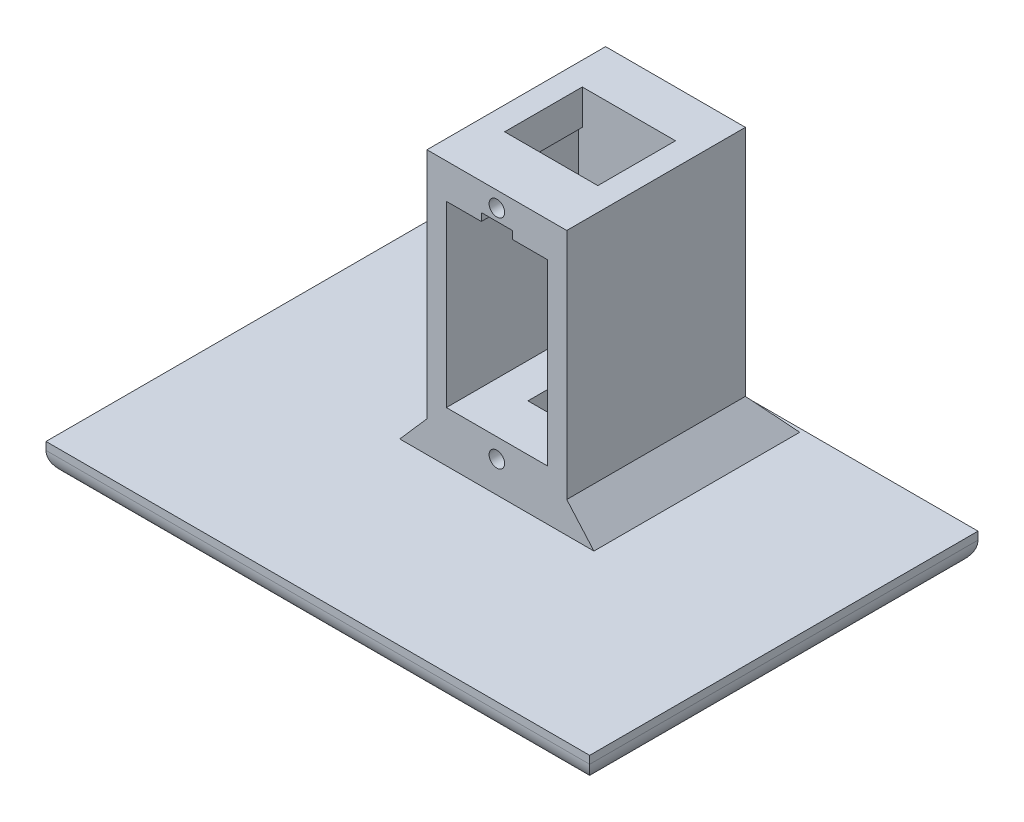
from build123d import *

# Parameters (mm, degrees)
BOSS_EXTRUDE1_DEPTH     = 22
SKETCH2_W               = 18.000000089
SKETCH2_H               = 20
BOSS_EXTRUDE2_DEPTH     = 7
SKETCH3_W               = 70
SKETCH3_H               = 50
BOSS_EXTRUDE3_DEPTH     = 4
SKETCH31_W              = 18.000000089
SKETCH31_H              = 3
BOSS_EXTRUDE7_DEPTH     = 34
CUT_EXTRUDE1_REACH      = 52
CUT_EXTRUDE_THIN1_REACH = 72
SKETCH7_W               = 25.000000089
SKETCH7_H               = 30
SKETCH8_W               = 18.000000089
SKETCH8_H               = 23
CUT_EXTRUDE2_DEPTH      = 27.000000055
CUT_EXTRUDE2_DEPTH_BACK = 45.000000145
SKETCH10_R              = 1
CUT_EXTRUDE3_DEPTH      = 10
SKETCH12_W              = 4
SKETCH12_H              = 5
CUT_EXTRUDE4_DEPTH      = 4
SKETCH13_W              = 18.000000089
SKETCH13_H              = 23
BOSS_EXTRUDE4_DEPTH     = 5
SKETCH14_R              = 1
CUT_EXTRUDE5_DEPTH      = 10
CUT_EXTRUDE6_REACH      = 40
CUT_EXTRUDE10_START     = -17
SKETCH29_W              = 13
SKETCH29_H              = 23
CUT_EXTRUDE10_DEPTH     = 17
SKETCH30_W              = 4
SKETCH30_H              = 1
CUT_EXTRUDE11_DEPTH     = 7
SKETCH21_R              = 5
CUT_EXTRUDE12_DEPTH     = 6
SKETCH32_R              = 4.999999958
BOSS_EXTRUDE8_DEPTH     = 2
CUT_EXTRUDE13_REACH     = 44.05
SKETCH33_R              = 1.5
SKETCH34_R              = 2.5
CUT_EXTRUDE14_DEPTH     = 1


with BuildPart() as part:
    # Sketch1 → Boss-Extrude1 (new body)
    with BuildSketch(Plane.XZ.offset(109.542579658)):
        Polygon((23.483775445, -24.37606884), (23.483775445, -44.37606884), (5.483775356, -44.37606884), (5.483775356, -24.37606884), (8.483775356, -24.37606884), (8.483775445, -41.37606884), (20.483775445, -41.37606884), (20.483775445, -24.37606884), align=None)
    extrude(amount=-BOSS_EXTRUDE1_DEPTH)

    # Sketch2 → Boss-Extrude2 (add)
    with BuildSketch(Plane.XZ.offset(109.542579658)):
        with Locations((14.483775401, -34.37606884)):
            Rectangle(SKETCH2_W, SKETCH2_H)
    extrude(amount=BOSS_EXTRUDE2_DEPTH)

    # Sketch3 → Boss-Extrude3 (add)
    with BuildSketch(Plane.XZ.offset(116.542579658)):
        with Locations((14.4837754, -26.325627156)):
            Rectangle(SKETCH3_W, SKETCH3_H)
    extrude(amount=BOSS_EXTRUDE3_DEPTH)

    # Sketch31 → Boss-Extrude7 (add)
    with BuildSketch(Plane(origin=(0, -116.542579658, 0), x_dir=(1, 0, 0), z_dir=(0, 1, 0))):
        with Locations((14.483775401, 45.87606884)):
            Rectangle(SKETCH31_W, SKETCH31_H)
    extrude(amount=BOSS_EXTRUDE7_DEPTH)

    # Sketch4 → Cut-Extrude1 (cut, up to next)
    with BuildSketch(Plane(origin=(0, 0, -51.325627156), x_dir=(-1, 0, 0), z_dir=(0, 0, -1)), mode=Mode.PRIVATE) as cut_extrude1_sk1:
        with BuildLine():
            Line((-49.4837754, -117.542579658), (-49.4837754, -120.542579658))
            Line((-49.4837754, -120.542579658), (-46.4837754, -120.542579658))
            ThreePointArc((-46.4837754, -120.542579658), (-48.605095744, -119.663900001), (-49.4837754, -117.542579658))
        make_face()
    cut_extrude1_tool1 = extrude(cut_extrude1_sk1.sketch, amount=-CUT_EXTRUDE1_REACH, mode=Mode.PRIVATE) & part.part
    add(cut_extrude1_tool1.solids().sort_by_distance((48.813672, -119.872476, -51.325627))[0], mode=Mode.SUBTRACT)
    # Sketch4 → Cut-Extrude1 (cut, up to next)
    with BuildSketch(Plane(origin=(0, 0, -51.325627156), x_dir=(-1, 0, 0), z_dir=(0, 0, -1)), mode=Mode.PRIVATE) as cut_extrude1_sk2:
        with BuildLine():
            Line((17.5162246, -120.542579658), (20.5162246, -120.542579658))
            Line((20.5162246, -120.542579658), (20.5162246, -117.542579658))
            ThreePointArc((20.5162246, -117.542579658), (19.637544943, -119.663900001), (17.5162246, -120.542579658))
        make_face()
    cut_extrude1_tool2 = extrude(cut_extrude1_sk2.sketch, amount=-CUT_EXTRUDE1_REACH, mode=Mode.PRIVATE) & part.part
    add(cut_extrude1_tool2.solids().sort_by_distance((-19.846121, -119.872476, -51.325627))[0], mode=Mode.SUBTRACT)

    # Sketch6 → Cut-Extrude-Thin1 (cut, up to next)
    with BuildSketch(Plane.ZY.offset(20.5162246), mode=Mode.PRIVATE) as cut_extrude_thin1_sk1:
        with BuildLine():
            ThreePointArc((-4.325627156, -120.542579658), (-2.204306812, -119.663900001), (-1.325627156, -117.542579658))
            Line((-1.325627156, -117.542579658), (8.674372844, -117.542579658))
            ThreePointArc((8.674372844, -117.542579658), (4.866761, -126.734967813), (-4.325627156, -130.542579658))
            Line((-4.325627156, -130.542579658), (-4.325627156, -120.542579658))
        make_face()
    cut_extrude_thin1_tool1 = extrude(cut_extrude_thin1_sk1.sketch, amount=-CUT_EXTRUDE_THIN1_REACH, mode=Mode.PRIVATE) & part.part
    add(cut_extrude_thin1_tool1.solids().sort_by_distance((-20.516225, -123.298683, 1.430477))[0], mode=Mode.SUBTRACT)
    # Sketch6 → Cut-Extrude-Thin1 (cut, up to next)
    with BuildSketch(Plane.ZY.offset(20.5162246), mode=Mode.PRIVATE) as cut_extrude_thin1_sk2:
        with BuildLine():
            ThreePointArc((-51.325627156, -117.542579658), (-50.446947499, -119.663900001), (-48.325627156, -120.542579658))
            Line((-48.325627156, -120.542579658), (-48.325627156, -130.542579658))
            ThreePointArc((-48.325627156, -130.542579658), (-57.518015311, -126.734967813), (-61.325627156, -117.542579658))
            Line((-61.325627156, -117.542579658), (-51.325627156, -117.542579658))
        make_face()
    cut_extrude_thin1_tool2 = extrude(cut_extrude_thin1_sk2.sketch, amount=-CUT_EXTRUDE_THIN1_REACH, mode=Mode.PRIVATE) & part.part
    add(cut_extrude_thin1_tool2.solids().sort_by_distance((-20.516225, -123.298683, -54.081731))[0], mode=Mode.SUBTRACT)

    # Sketch7 → Loft2 section 0
    with BuildSketch(Plane(origin=(0, -116.542579658, 0), x_dir=(1, 0, 0), z_dir=(0, 1, 0))):
        with Locations((14.483775401, 35.87606884)):
            Rectangle(SKETCH7_W, SKETCH7_H)
    # Sketch8 → Loft2 section 1
    with BuildSketch(Plane(origin=(0, -112.542579658, 0), x_dir=(1, 0, 0), z_dir=(0, 1, 0))):
        with Locations((14.483775401, 35.87606884)):
            Rectangle(SKETCH8_W, SKETCH8_H)
    loft()

    # Sketch9 → Cut-Extrude2 (cut, two sides)
    with BuildSketch(Plane.ZY.offset(-5.483775356)) as cut_extrude2_sk:
        Polygon((-24.37606884, -112.542579658), (-24.37606884, -116.542579658), (-20.87606884, -116.542579658), align=None)
    extrude(amount=CUT_EXTRUDE2_DEPTH, mode=Mode.SUBTRACT)
    extrude(cut_extrude2_sk.sketch, amount=-CUT_EXTRUDE2_DEPTH_BACK, mode=Mode.SUBTRACT)

    # Sketch10 → Cut-Extrude3 (cut)
    with BuildSketch(Plane.XY.offset(-24.37606884)):
        with Locations((14.483775445, -112.542579896)):
            Circle(SKETCH10_R)
    extrude(amount=-CUT_EXTRUDE3_DEPTH, mode=Mode.SUBTRACT)

    # Sketch12 → Cut-Extrude4 (cut)
    with BuildSketch(Plane.XY.offset(-34.37606884)):
        with Locations((14.483775445, -112.042579658)):
            Rectangle(SKETCH12_W, SKETCH12_H)
    extrude(amount=CUT_EXTRUDE4_DEPTH, mode=Mode.SUBTRACT)

    # Sketch13 → Boss-Extrude4 (add)
    with BuildSketch(Plane(origin=(0, -87.542579658, 0), x_dir=(1, 0, 0), z_dir=(0, 1, 0))):
        with Locations((14.483775401, 35.87606884)):
            Rectangle(SKETCH13_W, SKETCH13_H)
    extrude(amount=BOSS_EXTRUDE4_DEPTH)

    # Sketch14 → Cut-Extrude5 (cut)
    with BuildSketch(Plane.XY.offset(-24.37606884)):
        with Locations((14.483775445, -84.542579419)):
            Circle(SKETCH14_R)
    extrude(amount=-CUT_EXTRUDE5_DEPTH, mode=Mode.SUBTRACT)

    # Sketch16 → Cut-Extrude6 (cut, up to next)
    with BuildSketch(Plane(origin=(0, -82.542579658, 0), x_dir=(1, 0, 0), z_dir=(0, 1, 0)), mode=Mode.PRIVATE) as cut_extrude6_sk1:
        Polygon((14.4837754, 41.37606884), (8.4837754, 41.37606884), (8.4837754, 31.37606884), (20.4837754, 31.37606884), (20.4837754, 41.37606884), align=None)
    cut_extrude6_tool1 = extrude(cut_extrude6_sk1.sketch, amount=-CUT_EXTRUDE6_REACH, mode=Mode.PRIVATE) & part.part
    add(cut_extrude6_tool1.solids().sort_by_distance((14.483775, -82.54258, -36.376069))[0], mode=Mode.SUBTRACT)

    # Sketch29 → Cut-Extrude10 (cut)
    with BuildSketch(Plane.XY.offset(-24.37606884).offset(CUT_EXTRUDE10_START)):
        with Locations((14.483775445, -98.542579658)):
            Rectangle(SKETCH29_W, SKETCH29_H)
    extrude(amount=CUT_EXTRUDE10_DEPTH, mode=Mode.SUBTRACT)

    # Sketch30 → Cut-Extrude11 (cut)
    with BuildSketch(Plane.XY.offset(-24.37606884)):
        with Locations((14.483775445, -86.542579658)):
            Rectangle(SKETCH30_W, SKETCH30_H)
    extrude(amount=-CUT_EXTRUDE11_DEPTH, mode=Mode.SUBTRACT)

    # Sketch21 → Cut-Extrude12 (cut)
    with BuildSketch(Plane.XY.offset(-41.37606884)):
        with Locations((14.4837754, -93.542579583)):
            Circle(SKETCH21_R)
    extrude(amount=-CUT_EXTRUDE12_DEPTH, mode=Mode.SUBTRACT)

    # Sketch32 → Boss-Extrude8 (add)
    with BuildSketch(Plane.XY.offset(-41.37606884)):
        with Locations((14.483775445, -93.542579583)):
            Circle(SKETCH32_R)
    extrude(amount=-BOSS_EXTRUDE8_DEPTH)

    # Sketch33 → Cut-Extrude13 (cut, up to next)
    with BuildSketch(Plane(origin=(0, 0, -43.37606884), x_dir=(-1, 0, 0), z_dir=(0, 0, -1)), mode=Mode.PRIVATE) as cut_extrude13_sk1:
        with Locations((-14.4837754, -93.542579583)):
            Circle(SKETCH33_R)
    cut_extrude13_tool1 = extrude(cut_extrude13_sk1.sketch, amount=-CUT_EXTRUDE13_REACH, mode=Mode.PRIVATE) & part.part
    add(cut_extrude13_tool1.solids().sort_by_distance((14.483775, -93.54258, -43.376069))[0], mode=Mode.SUBTRACT)

    # Sketch34 → Cut-Extrude14 (cut)
    with BuildSketch(Plane.XY.offset(-41.37606884)):
        with Locations((14.4837754, -93.542579583)):
            Circle(SKETCH34_R)
    extrude(amount=-CUT_EXTRUDE14_DEPTH, mode=Mode.SUBTRACT)


solid = part.part
